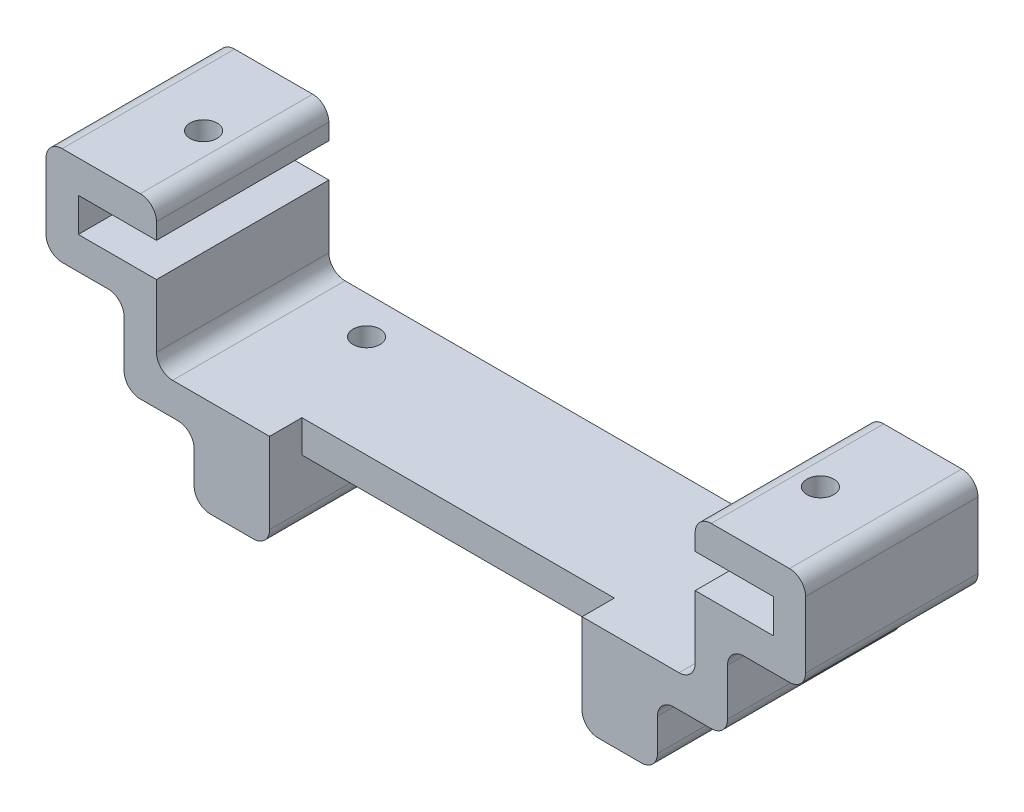
from build123d import *

# Parameters (mm, degrees)
BOSS_EXTRUDE1_DEPTH = 16
SKETCH2_R           = 1.25
CUT_EXTRUDE1_DEPTH  = 10
CUT_EXTRUDE2_REACH  = 24.5
SKETCH4_R           = 1.25
FILLET1_R           = 1.5
SKETCH8_W           = 29
SKETCH8_H           = 3
CUT_EXTRUDE3_DEPTH  = 10


with BuildPart() as part:
    # Sketch1 → Boss-Extrude1 (new body)
    with BuildSketch(Plane.XY):
        Polygon((-32.25, 0), (-32.25, -3.15), (-25, -3.15), (-25, -10.5), (25, -10.5), (25, -3.15), (32.25, -3.15), (32.25, 0), (25, 0), (25, 3), (35.25, 3), (35.25, -6.15), (28, -6.15), (28, -13.5), (21.5, -13.5), (21.5, -19.5), (14.5, -19.5), (14.5, -13.5), (-14.5, -13.5), (-14.5, -19.5), (-21.5, -19.5), (-21.5, -13.5), (-28, -13.5), (-28, -6.15), (-35.25, -6.15), (-35.25, 3), (-25, 3), (-25, 0), align=None)
    extrude(amount=BOSS_EXTRUDE1_DEPTH)

    # Sketch2 → Cut-Extrude1 (cut, through all)
    with BuildSketch(Plane(origin=(0, -10.5, 0), x_dir=(1, 0, 0), z_dir=(0, 1, 0))):
        with Locations((-18, -3.5)):
            Circle(SKETCH2_R)
        with Locations((18, -3.5)):
            Circle(SKETCH2_R)
    extrude(amount=-CUT_EXTRUDE1_DEPTH, mode=Mode.SUBTRACT)

    # Sketch4 → Cut-Extrude2 (cut, up to next)
    with BuildSketch(Plane(origin=(0, 3, 0), x_dir=(1, 0, 0), z_dir=(0, 1, 0)), mode=Mode.PRIVATE) as cut_extrude2_sk1:
        with Locations((-28.625, -8)):
            Circle(SKETCH4_R)
    cut_extrude2_tool1 = extrude(cut_extrude2_sk1.sketch, amount=-CUT_EXTRUDE2_REACH, mode=Mode.PRIVATE) & part.part
    add(cut_extrude2_tool1.solids().sort_by_distance((-28.625, 3, 8))[0], mode=Mode.SUBTRACT)
    # Sketch4 → Cut-Extrude2 (cut, up to next)
    with BuildSketch(Plane(origin=(0, 3, 0), x_dir=(1, 0, 0), z_dir=(0, 1, 0)), mode=Mode.PRIVATE) as cut_extrude2_sk2:
        with Locations((28.625, -8)):
            Circle(SKETCH4_R)
    cut_extrude2_tool2 = extrude(cut_extrude2_sk2.sketch, amount=-CUT_EXTRUDE2_REACH, mode=Mode.PRIVATE) & part.part
    add(cut_extrude2_tool2.solids().sort_by_distance((28.625, 3, 8))[0], mode=Mode.SUBTRACT)

    # Fillet1
    fillet1_edges = [part.edges().sort_by_distance(p)[0] for p in [
        (-25, -10.5, 8),
        (25, -10.5, 8),
        (25, 3, 8),
        (35.25, 3, 8),
        (35.25, -6.15, 8),
        (28, -6.15, 8),
        (28, -13.5, 8),
        (21.5, -13.5, 8),
        (21.5, -19.5, 8),
        (14.5, -19.5, 8),
        (-14.5, -19.5, 8),
        (-21.5, -19.5, 8),
        (-21.5, -13.5, 8),
        (-28, -13.5, 8),
        (-28, -6.15, 8),
        (-35.25, -6.15, 8),
        (-35.25, 3, 8),
        (-25, 3, 8),
    ]]
    fillet(fillet1_edges, radius=FILLET1_R)

    # Sketch8 → Cut-Extrude3 (cut, through all)
    with BuildSketch(Plane(origin=(0, -10.5, 0), x_dir=(1, 0, 0), z_dir=(0, 1, 0))):
        with Locations((0, -14.5)):
            Rectangle(SKETCH8_W, SKETCH8_H)
    extrude(amount=-CUT_EXTRUDE3_DEPTH, mode=Mode.SUBTRACT)


solid = part.part
